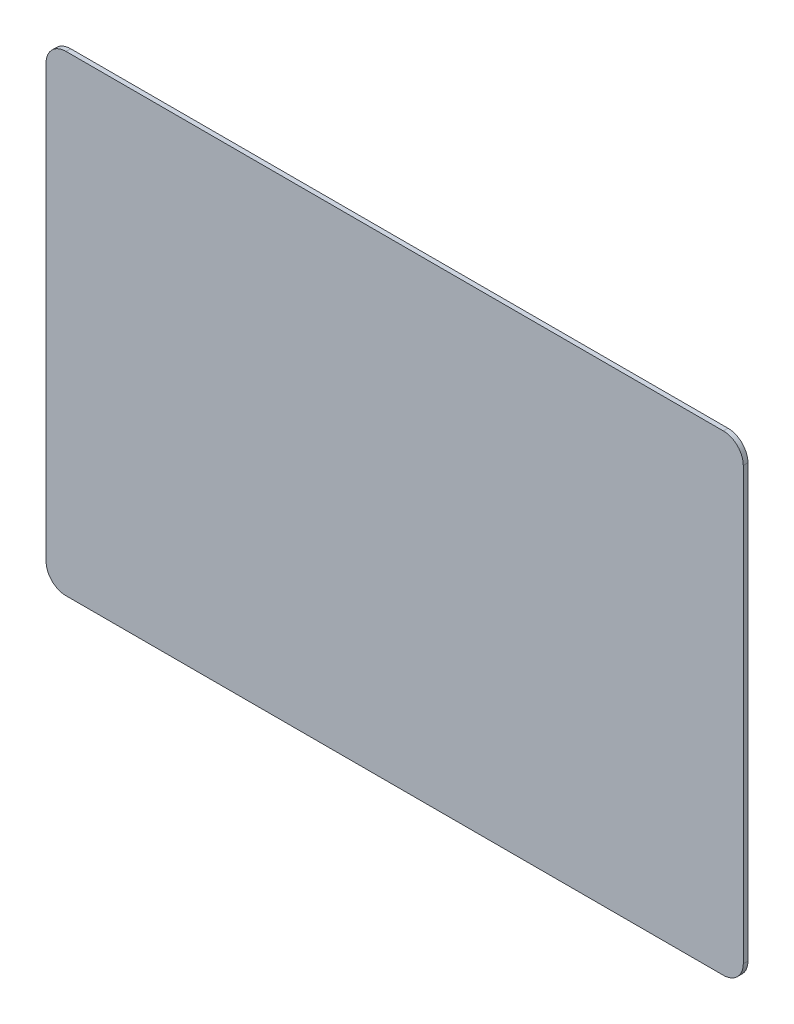
from build123d import *

# Parameters (mm, degrees)
BOSS_EXTRUDE1_DEPTH = 0.7


with BuildPart() as part:
    # Sketch1 → Boss-Extrude1 (new body)
    with BuildSketch(Plane.XY):
        with BuildLine():
            Line((52.5, -272.091788977), (52.5, -207.091788977))
            ThreePointArc((52.5, -207.091788977), (51.621320344, -204.970468633), (49.5, -204.091788977))
            Line((49.5, -204.091788977), (-49.5, -204.091788977))
            ThreePointArc((-49.5, -204.091788977), (-51.621320344, -204.970468633), (-52.5, -207.091788977))
            Line((-52.5, -207.091788977), (-52.5, -272.091788977))
            ThreePointArc((-52.5, -272.091788977), (-51.621320344, -274.213109321), (-49.5, -275.091788977))
            Line((-49.5, -275.091788977), (49.5, -275.091788977))
            ThreePointArc((49.5, -275.091788977), (51.621320344, -274.213109321), (52.5, -272.091788977))
        make_face()
    extrude(amount=BOSS_EXTRUDE1_DEPTH)


solid = part.part
